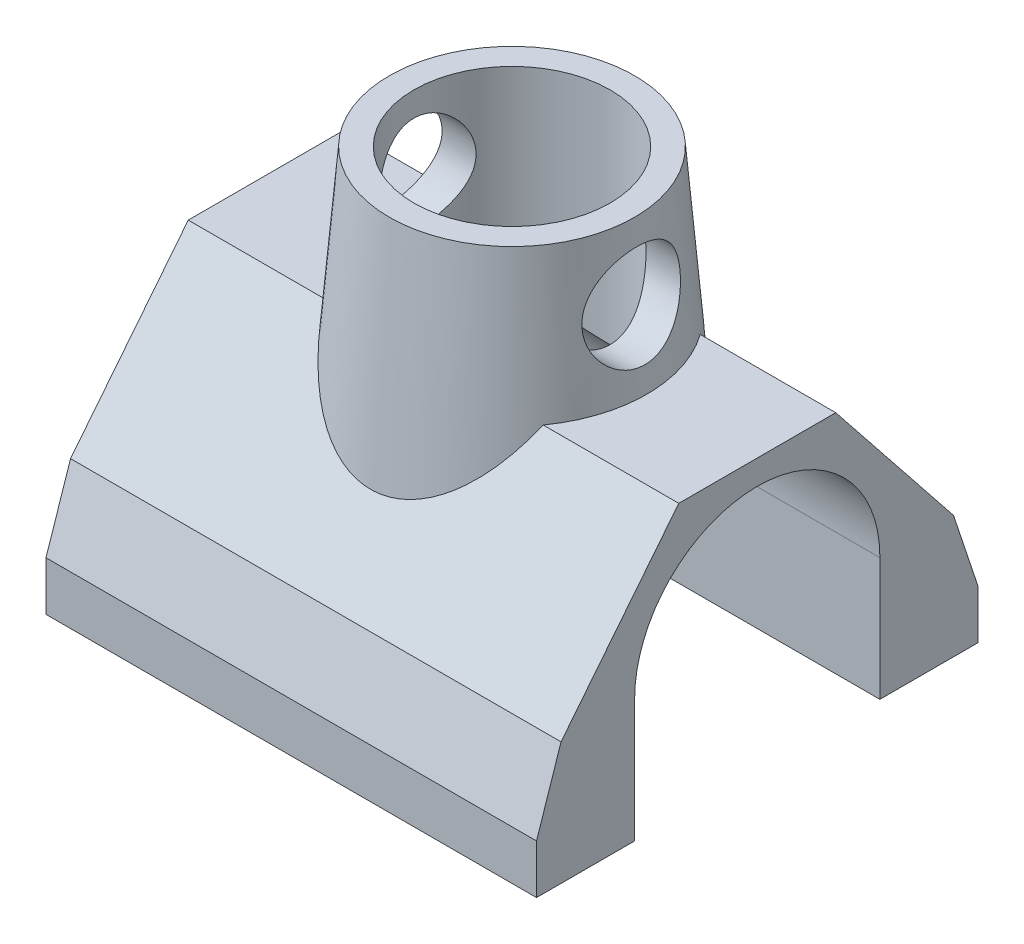
from build123d import *

# Parameters (mm, degrees)
EXTRUDE_1_DEPTH      = 50
EXTRUDE_1_DEPTH_BACK = 50
SKETCH_3_R           = 30
SKETCH_5_R           = 25
SKETCH_6_R           = 25
SKETCH_6_R_2         = 10
CUT_EXTRUDE_1_DEPTH  = 100
SKETCH_7_R           = 20
CUT_EXTRUDE_2_DEPTH  = 100


with BuildPart() as part:
    # Sketch 1 → Extrude 1 (new body, two sides)
    with BuildSketch(Plane(origin=(0, 0, 0), x_dir=(0, 0, -1), z_dir=(1, 0, 0))) as extrude_1_sk:
        with BuildLine():
            Line((-45, 9.886444909), (-45, -0.113555091))
            Line((-45, -0.113555091), (-25, -0.113555091))
            Line((-25, -0.113555091), (-25, 24.886444909))
            ThreePointArc((-25, 24.886444909), (0, 49.886444909), (25, 24.886444909))
            Line((25, 24.886444909), (25, -0.113555091))
            Line((25, -0.113555091), (45, -0.113555091))
            Line((45, -0.113555091), (45, 9.886444909))
            Line((45, 9.886444909), (40, 24.886444909))
            Line((40, 24.886444909), (16, 55))
            Line((16, 55), (-16, 55))
            Line((-16, 55), (-40, 24.886444909))
            Line((-40, 24.886444909), (-45, 9.886444909))
        make_face()
    extrude(amount=EXTRUDE_1_DEPTH)
    extrude(extrude_1_sk.sketch, amount=-EXTRUDE_1_DEPTH_BACK)

    # Sketch 3 → Loft 1 section 0
    with BuildSketch(Plane(origin=(0, 25, 0), x_dir=(1, 0, 0), z_dir=(0, 1, 0))):
        Circle(SKETCH_3_R)
    # Sketch 5 → Loft 1 section 1
    with BuildSketch(Plane(origin=(0, 85, 0), x_dir=(1, 0, 0), z_dir=(0, 1, 0))):
        Circle(SKETCH_5_R)
    loft()

    # Sketch 6 → Cut-Extrude 1 (cut)
    with BuildSketch(Plane.ZY.offset(50)):
        with Locations((0, 25)):
            Circle(SKETCH_6_R)
        with Locations((0, 70)):
            Circle(SKETCH_6_R_2)
    extrude(amount=-CUT_EXTRUDE_1_DEPTH, mode=Mode.SUBTRACT)

    # Sketch 7 → Cut-Extrude 2 (cut)
    with BuildSketch(Plane(origin=(0, 85, 0), x_dir=(1, 0, 0), z_dir=(0, 1, 0))):
        Circle(SKETCH_7_R)
    extrude(amount=-CUT_EXTRUDE_2_DEPTH, mode=Mode.SUBTRACT)


solid = part.part
